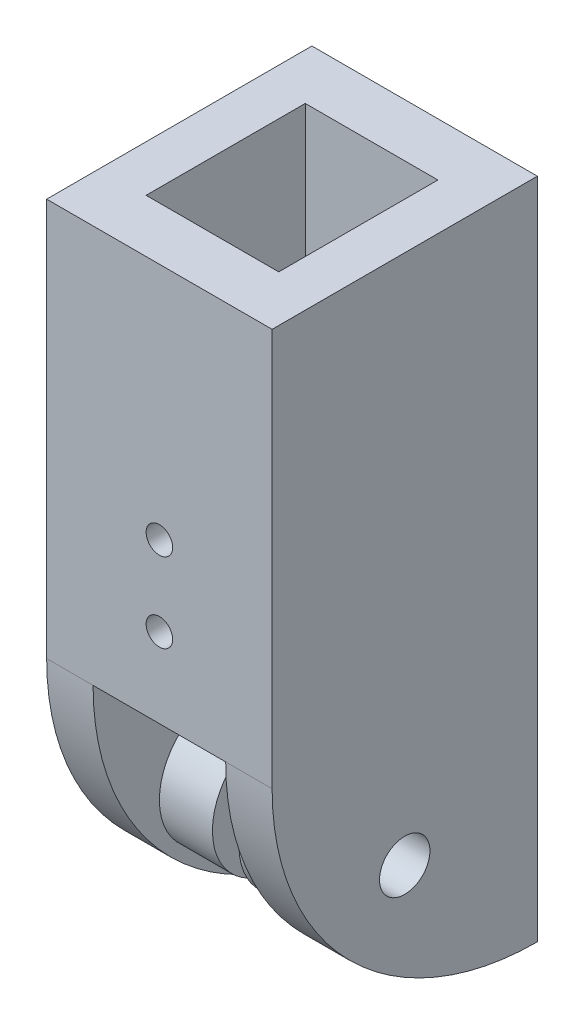
from build123d import *

# Parameters (mm, degrees)
SKETCH1_W               = 9
SKETCH1_H               = 10
SKETCH1_W_2             = 5
SKETCH1_H_2             = 6
BOSS_EXTRUDE1_DEPTH     = 15
BOSS_EXTRUDE2_DEPTH     = 2
SKETCH3_R               = 0.95
CUT_EXTRUDE2_DEPTH      = 1
CUT_EXTRUDE2_DEPTH_BACK = 10
SKETCH5_R               = 1.5
SKETCH5_R_2             = 0.95
BOSS_EXTRUDE3_DEPTH     = 5
SKETCH6_R               = 0.5
CUT_EXTRUDE3_DEPTH      = 11
SKETCH7_W               = 0.25
SKETCH7_H               = 25.68334021
SKETCH7_H_2             = 27.406815516
CUT_EXTRUDE4_DEPTH      = 1
CUT_EXTRUDE4_DEPTH_BACK = 11
SKETCH8_R               = 2.5
SKETCH8_R_2             = 1.5
BOSS_EXTRUDE4_DEPTH     = 2


with BuildPart() as part:
    # Sketch1 → Boss-Extrude1 (new body)
    with BuildSketch(Plane(origin=(0, 0, 0), x_dir=(1, 0, 0), z_dir=(0, 1, 0))):
        Rectangle(SKETCH1_W, SKETCH1_H)
        Rectangle(SKETCH1_W_2, SKETCH1_H_2, mode=Mode.SUBTRACT)
    extrude(amount=BOSS_EXTRUDE1_DEPTH)

    # Sketch2 → Boss-Extrude2 (add)
    with BuildSketch(Plane(origin=(4.5, 0, 0), x_dir=(0, 0, -1), z_dir=(1, 0, 0))):
        with BuildLine():
            Line((5, -10), (5, 0))
            Line((5, 0), (-5, 0))
            ThreePointArc((-5, 0), (-2.071067812, -7.071067812), (5, -10))
        make_face()
    boss_extrude2 = extrude(amount=-BOSS_EXTRUDE2_DEPTH)

    # Mirror1: Boss-Extrude2 across plane
    add(boss_extrude2.mirror(Plane(origin=(0, 0, 0), x_dir=(0, 0, 1), z_dir=(1, 0, 0))))

    # Sketch3 → Cut-Extrude2 (cut, two sides)
    with BuildSketch(Plane(origin=(4.5, 0, 0), x_dir=(0, 0, -1), z_dir=(1, 0, 0))) as cut_extrude2_sk:
        with Locations((0, -5)):
            Circle(SKETCH3_R)
    extrude(amount=CUT_EXTRUDE2_DEPTH, mode=Mode.SUBTRACT)
    extrude(cut_extrude2_sk.sketch, amount=-CUT_EXTRUDE2_DEPTH_BACK, mode=Mode.SUBTRACT)

    # Sketch5 → Boss-Extrude3 (add)
    with BuildSketch(Plane(origin=(-2.5, 0, 0), x_dir=(0, 0, -1), z_dir=(1, 0, 0))):
        with Locations((0, -5)):
            Circle(SKETCH5_R)
        with Locations((0, -5)):
            Circle(SKETCH5_R_2, mode=Mode.SUBTRACT)
    extrude(amount=BOSS_EXTRUDE3_DEPTH)

    # Sketch6 → Cut-Extrude3 (cut, through all)
    with BuildSketch(Plane.XY.offset(5)):
        with Locations((0, 3)):
            Circle(SKETCH6_R)
        with Locations((0, 6)):
            Circle(SKETCH6_R)
    extrude(amount=-CUT_EXTRUDE3_DEPTH, mode=Mode.SUBTRACT)

    # Sketch7 → Cut-Extrude4 (cut, two sides)
    with BuildSketch(Plane.XY.offset(5)) as cut_extrude4_sk:
        with Locations((-4.375, 2.158329895)):
            Rectangle(SKETCH7_W, SKETCH7_H)
        with Locations((4.375, 1.296592242)):
            Rectangle(SKETCH7_W, SKETCH7_H_2)
    extrude(amount=CUT_EXTRUDE4_DEPTH, mode=Mode.SUBTRACT)
    extrude(cut_extrude4_sk.sketch, amount=-CUT_EXTRUDE4_DEPTH_BACK, mode=Mode.SUBTRACT)

    # Sketch8 → Boss-Extrude4 (add)
    with BuildSketch(Plane.ZY.offset(-2.5)):
        with Locations((0, -5)):
            Circle(SKETCH8_R)
        with Locations((0, -5)):
            Circle(SKETCH8_R_2, mode=Mode.SUBTRACT)
    boss_extrude4 = extrude(amount=BOSS_EXTRUDE4_DEPTH)

    # Mirror2: Boss-Extrude4 across plane
    add(boss_extrude4.mirror(Plane(origin=(0, 0, 0), x_dir=(0, 0, 1), z_dir=(1, 0, 0))))


solid = part.part
